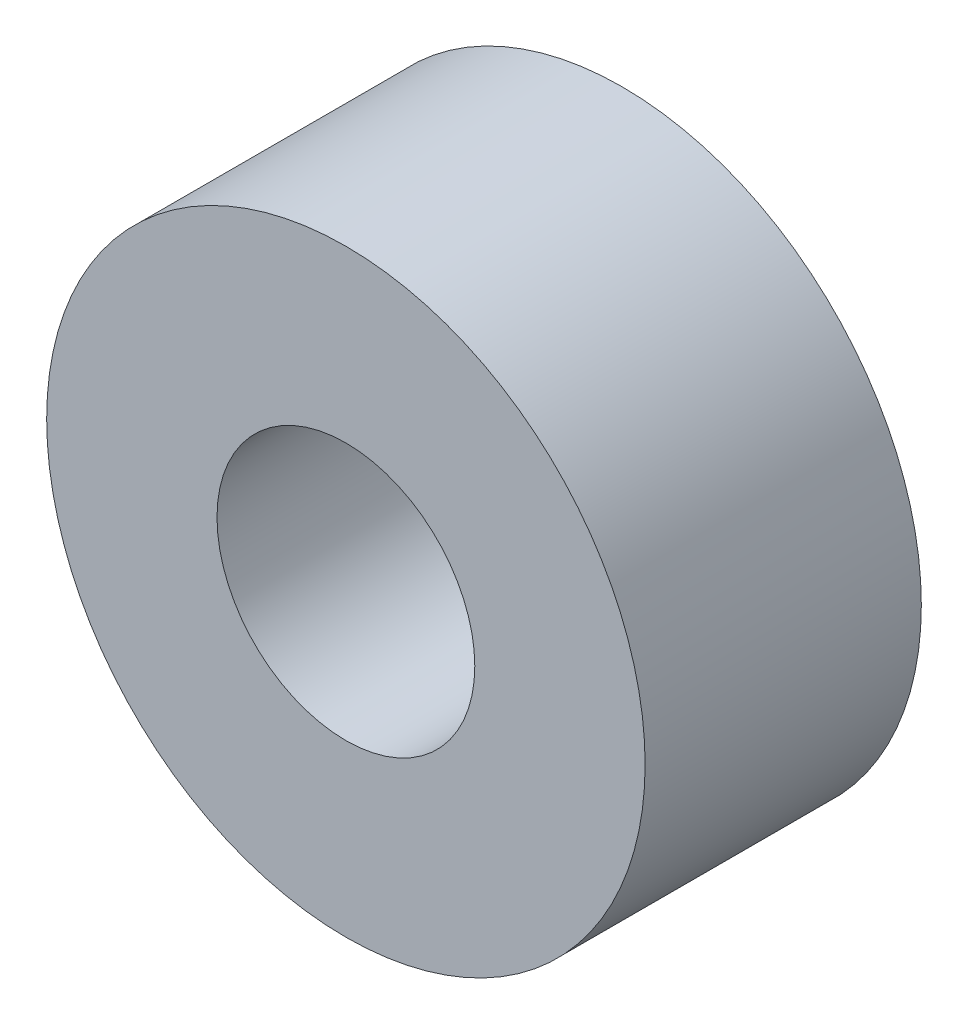
from build123d import *

# Parameters (mm, degrees)
ESQUISSE1_R        = 3.25
ESQUISSE1_R_2      = 1.4
BOSS_EXTRU_1_DEPTH = 3


with BuildPart() as part:
    # Esquisse1 → Boss.-Extru.1 (new body)
    with BuildSketch(Plane.XY):
        Circle(ESQUISSE1_R)
        Circle(ESQUISSE1_R_2, mode=Mode.SUBTRACT)
    extrude(amount=BOSS_EXTRU_1_DEPTH)


solid = part.part
